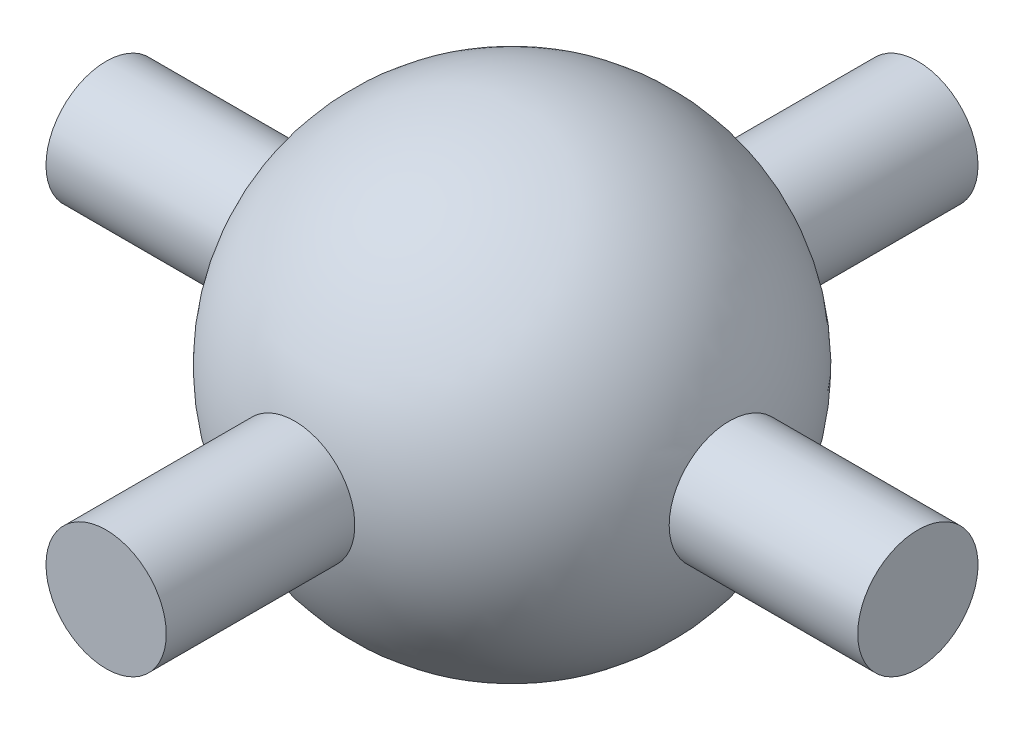
from build123d import *

# Parameters (mm, degrees)
SKETCH2_R           = 1
BOSS_EXTRUDE1_DEPTH = 6.75
CIRPATTERN1_COUNT   = 2
CIRPATTERN1_ANGLE   = 90


with BuildPart() as part:
    # Sketch1 → Revolve2 (revolve)
    with BuildSketch(Plane.XY):
        with BuildLine():
            Line((0, 3.75), (0, -3.75))
            ThreePointArc((0, -3.75), (3.75, 0), (0, 3.75))
        make_face()
    revolve(axis=Axis((0, 3.75, 0), (0, -1, 0)))

    # Sketch2 → Boss-Extrude1 (add, symmetric)
    with BuildSketch(Plane.XY):
        Circle(SKETCH2_R)
    boss_extrude1 = extrude(amount=BOSS_EXTRUDE1_DEPTH, both=True)

    # CirPattern1: Boss-Extrude1 ×2 about axis
    cirpattern1_axis = Axis((0, 4.125, 0), (0, -1, 0))
    for i in range(1, CIRPATTERN1_COUNT):
        add(boss_extrude1.rotate(cirpattern1_axis, i * CIRPATTERN1_ANGLE / (CIRPATTERN1_COUNT - 1)))


solid = part.part
